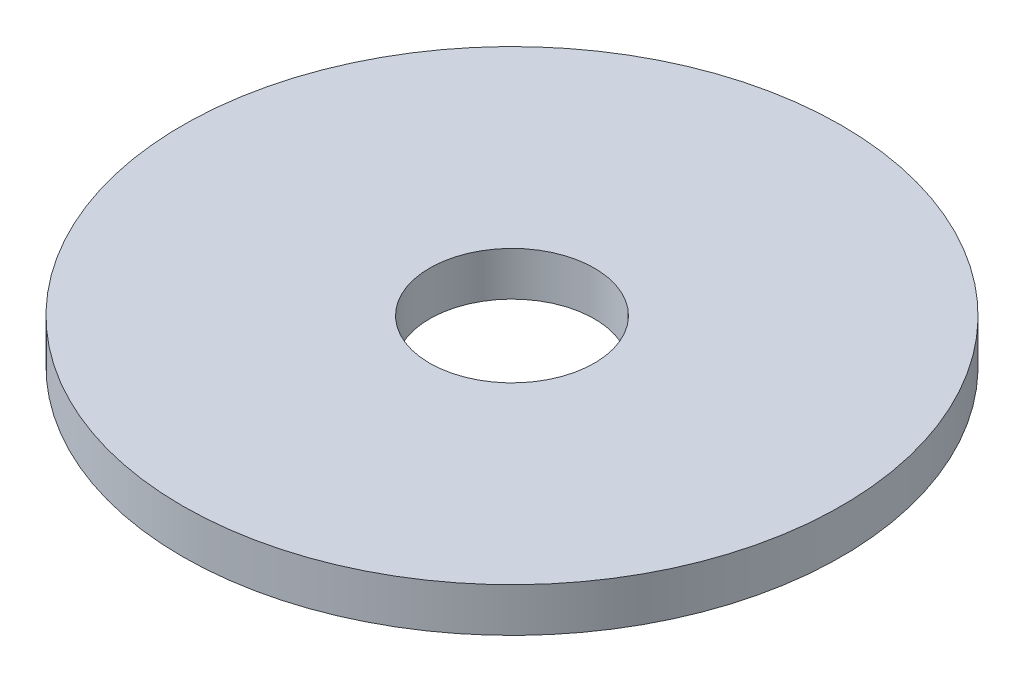
from build123d import *

# Parameters (mm, degrees)
SKETCH1_R           = 7.5
SKETCH1_R_2         = 1.875
BOSS_EXTRUDE1_DEPTH = 0.5


with BuildPart() as part:
    # Sketch1 → Boss-Extrude1 (new body, symmetric)
    with BuildSketch(Plane(origin=(0, 0, 0), x_dir=(1, 0, 0), z_dir=(0, 1, 0))):
        Circle(SKETCH1_R)
        Circle(SKETCH1_R_2, mode=Mode.SUBTRACT)
    extrude(amount=BOSS_EXTRUDE1_DEPTH, both=True)


solid = part.part
